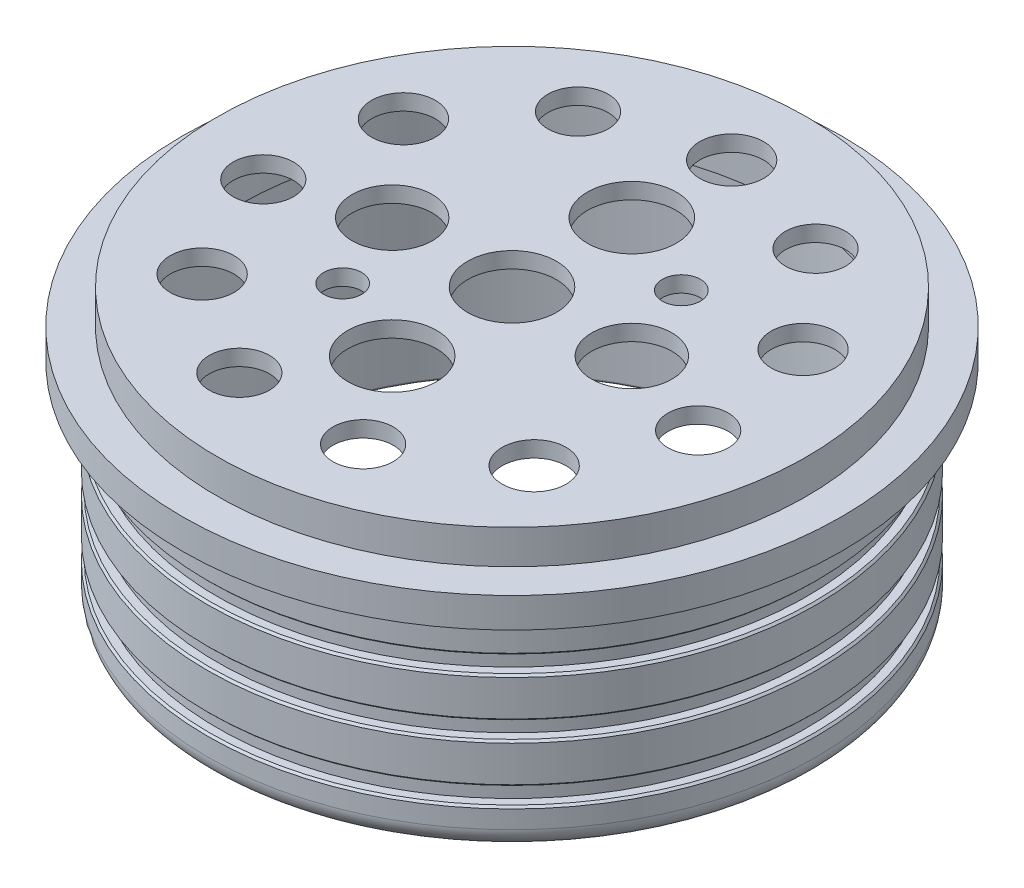
from build123d import *

# Parameters (mm, degrees)
CHAMFER1_SIZE      = 0.5
FILLET3_R          = 5
FILLET4_R          = 0.5
CUT_EXTRUDE1_REACH = 70.81
SKETCH3_R          = 11.125
SKETCH3_R_2        = 10.05
SKETCH3_R_3        = 8
SKETCH3_R_4        = 7.55
SKETCH3_R_5        = 4.7625
SKETCH4_R          = 68
CUT_EXTRUDE2_DEPTH = 12.06


with BuildPart() as part:
    # Sketch2 → Revolve1 (revolve)
    with BuildSketch(Plane.XY):
        Polygon((76.25, 52.75), (76.25, 42.75), (73.75, 42.75), (73.75, 38.5), (76.25, 38.5), (76.25, 28.5), (73.75, 28.5), (73.75, 24.25), (76.25, 24.25), (76.25, 14.25), (73.75, 14.25), (73.75, 10), (76.25, 10), (76.25, 0), (69.75, 0), (69.75, 52.75), (0, 52.75), (0, 60.25), (0, 68.810209945), (73.75, 68.810209945), (73.75, 60.25), (82.55, 60.25), (82.55, 52.75), align=None)
    revolve(axis=Axis((0, 0, 0), (0, 1, 0)))

    # Chamfer1
    chamfer1_edges = [part.edges().sort_by_distance(p)[0] for p in [
        (-76.25, 42.75, 0),
        (-76.25, 38.5, 0),
        (-76.25, 28.5, 0),
        (-76.25, 24.25, 0),
        (-76.25, 14.25, 0),
        (-76.25, 10, 0),
    ]]
    chamfer(chamfer1_edges, length=CHAMFER1_SIZE)

    # Fillet3
    fillet3_edges = [part.edges().sort_by_distance(p)[0] for p in [
        (-76.25, 0, 0),
    ]]
    fillet(fillet3_edges, radius=FILLET3_R)

    # Fillet4
    fillet4_edges = [part.edges().sort_by_distance(p)[0] for p in [
        (-69.75, 0, 0),
    ]]
    fillet(fillet4_edges, radius=FILLET4_R)

    # Sketch3 → Cut-Extrude1 (cut, up to next)
    with BuildSketch(Plane(origin=(0, 68.810209945, 0), x_dir=(1, 0, 0), z_dir=(0, 1, 0)), mode=Mode.PRIVATE) as cut_extrude1_sk1:
        Circle(SKETCH3_R)
    cut_extrude1_tool1 = extrude(cut_extrude1_sk1.sketch, amount=-CUT_EXTRUDE1_REACH, mode=Mode.PRIVATE) & part.part
    add(cut_extrude1_tool1.solids().sort_by_distance((0, 68.81021, 0))[0], mode=Mode.SUBTRACT)
    # Sketch3 → Cut-Extrude1 (cut, up to next)
    with BuildSketch(Plane(origin=(0, 68.810209945, 0), x_dir=(1, 0, 0), z_dir=(0, 1, 0)), mode=Mode.PRIVATE) as cut_extrude1_sk2:
        with Locations((30, 0)):
            Circle(SKETCH3_R_2)
    cut_extrude1_tool2 = extrude(cut_extrude1_sk2.sketch, amount=-CUT_EXTRUDE1_REACH, mode=Mode.PRIVATE) & part.part
    add(cut_extrude1_tool2.solids().sort_by_distance((30, 68.81021, 0))[0], mode=Mode.SUBTRACT)
    # Sketch3 → Cut-Extrude1 (cut, up to next)
    with BuildSketch(Plane(origin=(0, 68.810209945, 0), x_dir=(1, 0, 0), z_dir=(0, 1, 0)), mode=Mode.PRIVATE) as cut_extrude1_sk3:
        with Locations((0, -30)):
            Circle(SKETCH3_R)
    cut_extrude1_tool3 = extrude(cut_extrude1_sk3.sketch, amount=-CUT_EXTRUDE1_REACH, mode=Mode.PRIVATE) & part.part
    add(cut_extrude1_tool3.solids().sort_by_distance((0, 68.81021, 30))[0], mode=Mode.SUBTRACT)
    # Sketch3 → Cut-Extrude1 (cut, up to next)
    with BuildSketch(Plane(origin=(0, 68.810209945, 0), x_dir=(1, 0, 0), z_dir=(0, 1, 0)), mode=Mode.PRIVATE) as cut_extrude1_sk4:
        with Locations((-30, 0)):
            Circle(SKETCH3_R_2)
    cut_extrude1_tool4 = extrude(cut_extrude1_sk4.sketch, amount=-CUT_EXTRUDE1_REACH, mode=Mode.PRIVATE) & part.part
    add(cut_extrude1_tool4.solids().sort_by_distance((-30, 68.81021, 0))[0], mode=Mode.SUBTRACT)
    # Sketch3 → Cut-Extrude1 (cut, up to next)
    with BuildSketch(Plane(origin=(0, 68.810209945, 0), x_dir=(1, 0, 0), z_dir=(0, 1, 0)), mode=Mode.PRIVATE) as cut_extrude1_sk5:
        with Locations((0, 30)):
            Circle(SKETCH3_R)
    cut_extrude1_tool5 = extrude(cut_extrude1_sk5.sketch, amount=-CUT_EXTRUDE1_REACH, mode=Mode.PRIVATE) & part.part
    add(cut_extrude1_tool5.solids().sort_by_distance((0, 68.81021, -30))[0], mode=Mode.SUBTRACT)
    # Sketch3 → Cut-Extrude1 (cut, up to next)
    with BuildSketch(Plane(origin=(0, 68.810209945, 0), x_dir=(1, 0, 0), z_dir=(0, 1, 0)), mode=Mode.PRIVATE) as cut_extrude1_sk6:
        with Locations((0, 55)):
            Circle(SKETCH3_R_3)
    cut_extrude1_tool6 = extrude(cut_extrude1_sk6.sketch, amount=-CUT_EXTRUDE1_REACH, mode=Mode.PRIVATE) & part.part
    add(cut_extrude1_tool6.solids().sort_by_distance((0, 68.81021, -55))[0], mode=Mode.SUBTRACT)
    # Sketch3 → Cut-Extrude1 (cut, up to next)
    with BuildSketch(Plane(origin=(0, 68.810209945, 0), x_dir=(1, 0, 0), z_dir=(0, 1, 0)), mode=Mode.PRIVATE) as cut_extrude1_sk7:
        with Locations((29.73524496, 46.268944306)):
            Circle(SKETCH3_R_4)
    cut_extrude1_tool7 = extrude(cut_extrude1_sk7.sketch, amount=-CUT_EXTRUDE1_REACH, mode=Mode.PRIVATE) & part.part
    add(cut_extrude1_tool7.solids().sort_by_distance((29.735245, 68.81021, -46.268944))[0], mode=Mode.SUBTRACT)
    # Sketch3 → Cut-Extrude1 (cut, up to next)
    with BuildSketch(Plane(origin=(0, 68.810209945, 0), x_dir=(1, 0, 0), z_dir=(0, 1, 0)), mode=Mode.PRIVATE) as cut_extrude1_sk8:
        with Locations((50.029759744, 22.847825715)):
            Circle(SKETCH3_R_3)
    cut_extrude1_tool8 = extrude(cut_extrude1_sk8.sketch, amount=-CUT_EXTRUDE1_REACH, mode=Mode.PRIVATE) & part.part
    add(cut_extrude1_tool8.solids().sort_by_distance((50.02976, 68.81021, -22.847826))[0], mode=Mode.SUBTRACT)
    # Sketch3 → Cut-Extrude1 (cut, up to next)
    with BuildSketch(Plane(origin=(0, 68.810209945, 0), x_dir=(1, 0, 0), z_dir=(0, 1, 0)), mode=Mode.PRIVATE) as cut_extrude1_sk9:
        with Locations((54.440179303, -7.827316105)):
            Circle(SKETCH3_R_4)
    cut_extrude1_tool9 = extrude(cut_extrude1_sk9.sketch, amount=-CUT_EXTRUDE1_REACH, mode=Mode.PRIVATE) & part.part
    add(cut_extrude1_tool9.solids().sort_by_distance((54.440179, 68.81021, 7.827316))[0], mode=Mode.SUBTRACT)
    # Sketch3 → Cut-Extrude1 (cut, up to next)
    with BuildSketch(Plane(origin=(0, 68.810209945, 0), x_dir=(1, 0, 0), z_dir=(0, 1, 0)), mode=Mode.PRIVATE) as cut_extrude1_sk10:
        with Locations((41.566226589, -36.017340367)):
            Circle(SKETCH3_R_3)
    cut_extrude1_tool10 = extrude(cut_extrude1_sk10.sketch, amount=-CUT_EXTRUDE1_REACH, mode=Mode.PRIVATE) & part.part
    add(cut_extrude1_tool10.solids().sort_by_distance((41.566227, 68.81021, 36.01734))[0], mode=Mode.SUBTRACT)
    # Sketch3 → Cut-Extrude1 (cut, up to next)
    with BuildSketch(Plane(origin=(0, 68.810209945, 0), x_dir=(1, 0, 0), z_dir=(0, 1, 0)), mode=Mode.PRIVATE) as cut_extrude1_sk11:
        with Locations((15.495290626, -52.772113549)):
            Circle(SKETCH3_R_4)
    cut_extrude1_tool11 = extrude(cut_extrude1_sk11.sketch, amount=-CUT_EXTRUDE1_REACH, mode=Mode.PRIVATE) & part.part
    add(cut_extrude1_tool11.solids().sort_by_distance((15.495291, 68.81021, 52.772114))[0], mode=Mode.SUBTRACT)
    # Sketch3 → Cut-Extrude1 (cut, up to next)
    with BuildSketch(Plane(origin=(0, 68.810209945, 0), x_dir=(1, 0, 0), z_dir=(0, 1, 0)), mode=Mode.PRIVATE) as cut_extrude1_sk12:
        with Locations((-15.495290626, -52.772113549)):
            Circle(SKETCH3_R_4)
    cut_extrude1_tool12 = extrude(cut_extrude1_sk12.sketch, amount=-CUT_EXTRUDE1_REACH, mode=Mode.PRIVATE) & part.part
    add(cut_extrude1_tool12.solids().sort_by_distance((-15.495291, 68.81021, 52.772114))[0], mode=Mode.SUBTRACT)
    # Sketch3 → Cut-Extrude1 (cut, up to next)
    with BuildSketch(Plane(origin=(0, 68.810209945, 0), x_dir=(1, 0, 0), z_dir=(0, 1, 0)), mode=Mode.PRIVATE) as cut_extrude1_sk13:
        with Locations((-41.566226589, -36.017340367)):
            Circle(SKETCH3_R_3)
    cut_extrude1_tool13 = extrude(cut_extrude1_sk13.sketch, amount=-CUT_EXTRUDE1_REACH, mode=Mode.PRIVATE) & part.part
    add(cut_extrude1_tool13.solids().sort_by_distance((-41.566227, 68.81021, 36.01734))[0], mode=Mode.SUBTRACT)
    # Sketch3 → Cut-Extrude1 (cut, up to next)
    with BuildSketch(Plane(origin=(0, 68.810209945, 0), x_dir=(1, 0, 0), z_dir=(0, 1, 0)), mode=Mode.PRIVATE) as cut_extrude1_sk14:
        with Locations((-54.440179303, -7.827316105)):
            Circle(SKETCH3_R_4)
    cut_extrude1_tool14 = extrude(cut_extrude1_sk14.sketch, amount=-CUT_EXTRUDE1_REACH, mode=Mode.PRIVATE) & part.part
    add(cut_extrude1_tool14.solids().sort_by_distance((-54.440179, 68.81021, 7.827316))[0], mode=Mode.SUBTRACT)
    # Sketch3 → Cut-Extrude1 (cut, up to next)
    with BuildSketch(Plane(origin=(0, 68.810209945, 0), x_dir=(1, 0, 0), z_dir=(0, 1, 0)), mode=Mode.PRIVATE) as cut_extrude1_sk15:
        with Locations((-50.029759744, 22.847825715)):
            Circle(SKETCH3_R_3)
    cut_extrude1_tool15 = extrude(cut_extrude1_sk15.sketch, amount=-CUT_EXTRUDE1_REACH, mode=Mode.PRIVATE) & part.part
    add(cut_extrude1_tool15.solids().sort_by_distance((-50.02976, 68.81021, -22.847826))[0], mode=Mode.SUBTRACT)
    # Sketch3 → Cut-Extrude1 (cut, up to next)
    with BuildSketch(Plane(origin=(0, 68.810209945, 0), x_dir=(1, 0, 0), z_dir=(0, 1, 0)), mode=Mode.PRIVATE) as cut_extrude1_sk16:
        with Locations((-29.73524496, 46.268944306)):
            Circle(SKETCH3_R_4)
    cut_extrude1_tool16 = extrude(cut_extrude1_sk16.sketch, amount=-CUT_EXTRUDE1_REACH, mode=Mode.PRIVATE) & part.part
    add(cut_extrude1_tool16.solids().sort_by_distance((-29.735245, 68.81021, -46.268944))[0], mode=Mode.SUBTRACT)
    # Sketch3 → Cut-Extrude1 (cut, up to next)
    with BuildSketch(Plane(origin=(0, 68.810209945, 0), x_dir=(1, 0, 0), z_dir=(0, 1, 0)), mode=Mode.PRIVATE) as cut_extrude1_sk17:
        with Locations((21.940611049, 20.459950802)):
            Circle(SKETCH3_R_5)
    cut_extrude1_tool17 = extrude(cut_extrude1_sk17.sketch, amount=-CUT_EXTRUDE1_REACH, mode=Mode.PRIVATE) & part.part
    add(cut_extrude1_tool17.solids().sort_by_distance((21.940611, 68.81021, -20.459951))[0], mode=Mode.SUBTRACT)
    # Sketch3 → Cut-Extrude1 (cut, up to next)
    with BuildSketch(Plane(origin=(0, 68.810209945, 0), x_dir=(1, 0, 0), z_dir=(0, 1, 0)), mode=Mode.PRIVATE) as cut_extrude1_sk18:
        with Locations((-21.940611049, -20.459950802)):
            Circle(SKETCH3_R_5)
    cut_extrude1_tool18 = extrude(cut_extrude1_sk18.sketch, amount=-CUT_EXTRUDE1_REACH, mode=Mode.PRIVATE) & part.part
    add(cut_extrude1_tool18.solids().sort_by_distance((-21.940611, 68.81021, 20.459951))[0], mode=Mode.SUBTRACT)

    # Sketch4 → Cut-Extrude2 (cut)
    with BuildSketch(Plane.XZ.offset(-52.75)):
        Circle(SKETCH4_R)
    extrude(amount=-CUT_EXTRUDE2_DEPTH, mode=Mode.SUBTRACT)


solid = part.part
